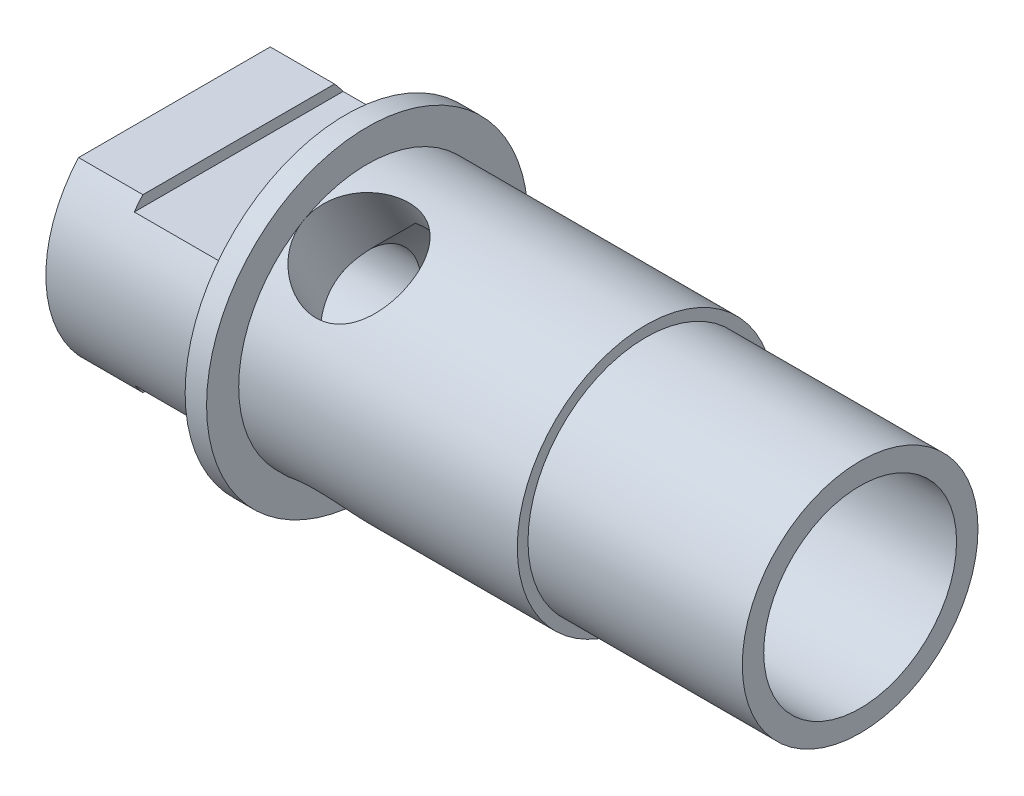
from build123d import *

# Parameters (mm, degrees)
ENL_V_MAT_EXTRU_1_DEPTH      = 8
ESQUISSE3_W                  = 5
ESQUISSE3_H                  = 10
ENL_V_MAT_EXTRU_2_DEPTH      = 0.5
ESQUISSE4_R                  = 2.5
ENL_V_MAT_EXTRU_3_DEPTH      = 7.5
R_P_TITION_CIRCULAIRE1_COUNT = 3


with BuildPart() as part:
    # Esquisse1 → Révolution1 (revolve)
    with BuildSketch(Plane.XY):
        Polygon((-2.5, 2.5), (-0.5, 4.5), (20.5, 4.5), (20.5, 5.5), (10.5, 5.5), (10.5, 6), (-2.5, 6), (-2.5, 7.5), (-3.5, 7.5), (-3.5, 3.93766302), (-3.5, 6), (-11.5, 6), (-11.5, 2.5), align=None)
    revolve(axis=Axis((-18.702181891, 0, 0), (1, 0, 0)))

    # Esquisse2 → Enlèv. mat.-Extru.1 (cut)
    with BuildSketch(Plane.ZY.offset(11.5)):
        with BuildLine():
            Line((-4.472135955, 4), (4.472135955, 4))
            ThreePointArc((4.472135955, 4), (0, 6), (-4.472135955, 4))
        make_face()
        with BuildLine():
            Line((-4.472135955, -4), (4.472135955, -4))
            ThreePointArc((4.472135955, -4), (0, -6), (-4.472135955, -4))
        make_face()
    extrude(amount=-ENL_V_MAT_EXTRU_1_DEPTH, mode=Mode.SUBTRACT)

    # Esquisse3 → Enlèv. mat.-Extru.2 (cut)
    with BuildSketch(Plane(origin=(0, 4, 0), x_dir=(1, 0, 0), z_dir=(0, 1, 0))):
        with Locations((-6, 0)):
            Rectangle(ESQUISSE3_W, ESQUISSE3_H)
    enl_v_mat_extru_2 = extrude(amount=-ENL_V_MAT_EXTRU_2_DEPTH, mode=Mode.SUBTRACT)

    # Symétrie1: Enlèv. mat.-Extru.2 across plane
    add(enl_v_mat_extru_2.mirror(Plane.ZX), mode=Mode.SUBTRACT)

    # Esquisse4 → Enlèv. mat.-Extru.3 (cut)
    with BuildSketch(Plane.XY):
        Circle(ESQUISSE4_R)
    enl_v_mat_extru_3 = extrude(amount=-ENL_V_MAT_EXTRU_3_DEPTH, mode=Mode.SUBTRACT)

    # Répétition circulaire1: Enlèv. mat.-Extru.3 ×3 about axis
    r_p_tition_circulaire1_axis = Axis((-18.702181891, 0, 0), (-1, 0, 0))
    for i in range(1, R_P_TITION_CIRCULAIRE1_COUNT):
        add(enl_v_mat_extru_3.rotate(r_p_tition_circulaire1_axis, i * 360 / R_P_TITION_CIRCULAIRE1_COUNT), mode=Mode.SUBTRACT)


solid = part.part
